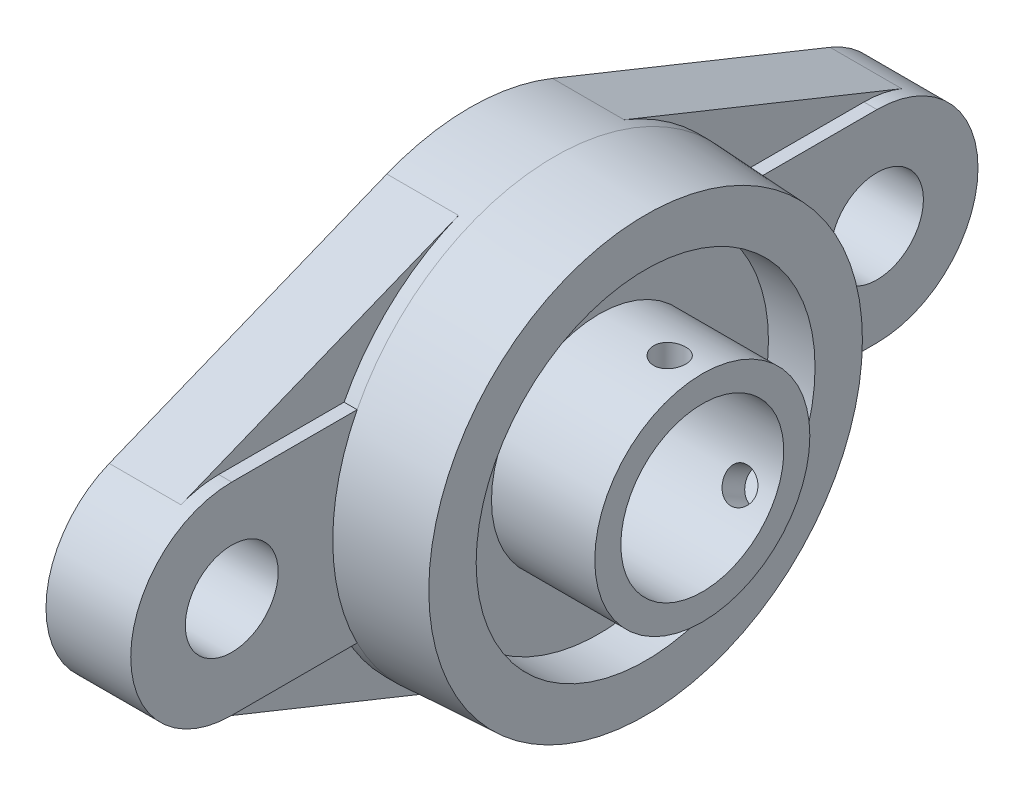
from build123d import *

# Parameters (mm, degrees)
EXTRUDE_1_DEPTH               = 2
EXTRUDE_2_DEPTH               = 11
SKETCH_3_R                    = 34
EXTRUDE_3_DEPTH               = 14
EXTRUDE_3_TAPER               = 3
HOLE_WIZARD_M45_1_D           = 52
HOLE_WIZARD_M45_1_DEPTH       = 7.15
SKETCH_6_W                    = 15.85
SKETCH_6_H                    = 16.5
HOLE_WIZARD_14_25_14_25_1_D   = 14.25
HOLE_WIZARD_M24_1_D           = 25
HOLE_WIZARD_M24_1_DEPTH       = 35.7
HOLE_WIZARD_M24_1_CBORE_D     = 52
HOLE_WIZARD_M24_1_CBORE_DEPTH = 2
SKETCH_11_W                   = 2.4585
SKETCH_11_H                   = 61.03580457
HOLE_WIZARD_2_D               = 4.917
HOLE_WIZARD_2_DEPTH           = 21.744153324


with BuildPart() as part:
    # 草图1 → 凸台-拉伸1 (new body)
    with BuildSketch(Plane(origin=(13, 0, 0), x_dir=(0, 0, -1), z_dir=(1, 0, 0))):
        with BuildLine():
            Line((49.5, 15.5), (30.261361503, 15.5))
            ThreePointArc((30.261361503, 15.5), (0, 34), (-30.261361503, 15.5))
            Line((-30.261361503, 15.5), (-49.5, 15.5))
            ThreePointArc((-49.5, 15.5), (-65, 0), (-49.5, -15.5))
            Line((-49.5, -15.5), (-30.261361503, -15.5))
            ThreePointArc((-30.261361503, -15.5), (0, -34), (30.261361503, -15.5))
            Line((30.261361503, -15.5), (49.5, -15.5))
            ThreePointArc((49.5, -15.5), (65, 0), (49.5, 15.5))
        make_face()
    extrude(amount=-EXTRUDE_1_DEPTH)

    # 草图2 → 凸台-拉伸2 (add)
    with BuildSketch(Plane.ZY.offset(-11)):
        with BuildLine():
            Line((12.707070707, 31.536175324), (55.292929293, 14.376785809))
            ThreePointArc((55.292929293, 14.376785809), (65, 0), (55.292929293, -14.376785809))
            Line((55.292929293, -14.376785809), (12.707070707, -31.536175324))
            ThreePointArc((12.707070707, -31.536175324), (0, -34), (-12.707070707, -31.536175324))
            Line((-12.707070707, -31.536175324), (-55.292929293, -14.376785809))
            ThreePointArc((-55.292929293, -14.376785809), (-65, 0), (-55.292929293, 14.376785809))
            Line((-55.292929293, 14.376785809), (-12.707070707, 31.536175324))
            ThreePointArc((-12.707070707, 31.536175324), (0, 34), (12.707070707, 31.536175324))
        make_face()
    extrude(amount=EXTRUDE_2_DEPTH)

    # 草图3 → 凸台-拉伸3 (add)
    with BuildSketch(Plane(origin=(13, 0, 0), x_dir=(0, 0, -1), z_dir=(1, 0, 0))):
        Circle(SKETCH_3_R)
    extrude(amount=EXTRUDE_3_DEPTH, taper=EXTRUDE_3_TAPER)

    # M45 间隙孔1
    with Locations(Plane(origin=(27, 0, 0), x_dir=(0, 0, -1), z_dir=(1, 0, 0))):
        with Locations((0, 0)):
            Hole(HOLE_WIZARD_M45_1_D / 2, depth=HOLE_WIZARD_M45_1_DEPTH)

    # 草图6 → 旋转1 (revolve)
    with BuildSketch(Plane(origin=(0, 0, 0), x_dir=(-1, 0, 0), z_dir=(0, 0, -1))):
        with Locations((-27.775, 8.25)):
            Rectangle(SKETCH_6_W, SKETCH_6_H)
    revolve(axis=Axis((35.7, 0, 0), (-1, 0, 0)))

    # Ø14.25 (14.25) 直径孔1 (through all)
    with Locations(Plane(origin=(13, 0, 0), x_dir=(0, 0, -1), z_dir=(1, 0, 0))):
        with Locations((-49.5, 0), (49.5, 0)):
            Hole(HOLE_WIZARD_14_25_14_25_1_D / 2)

    # M24 六角头螺栓的柱形沉头孔1
    with Locations(Plane.ZY):
        with Locations((0, 0)):
            CounterBoreHole(HOLE_WIZARD_M24_1_D / 2, HOLE_WIZARD_M24_1_CBORE_D / 2, HOLE_WIZARD_M24_1_CBORE_DEPTH, depth=HOLE_WIZARD_M24_1_DEPTH)

    # 草图11 → 孔1 (revolve, cut)
    with BuildSketch(Plane(origin=(30.7, -6.127923338, -10.613874566), x_dir=(0, -0.866025404, 0.5), z_dir=(1, 0, 0))):
        with Locations((1.22925, 30.517902285)):
            Rectangle(SKETCH_11_W, SKETCH_11_H)
    revolve(axis=Axis((30.7, -61.127923338, -105.876668983), (0, 0.5, 0.866025404)), mode=Mode.SUBTRACT)

    # 孔2
    with Locations(Plane(origin=(0, 12.255846676, 0), x_dir=(-1, 0, 0), z_dir=(0, -1, 0))):
        with Locations((-30.7, 0)):
            Hole(HOLE_WIZARD_2_D / 2, depth=HOLE_WIZARD_2_DEPTH)


solid = part.part
